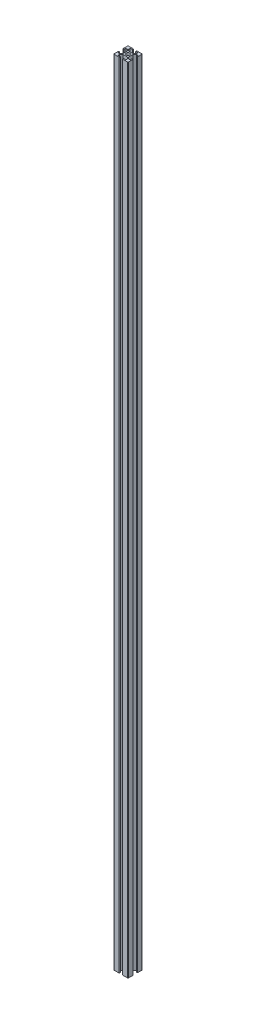
from build123d import *

# Parameters (mm, degrees)
SKETCH_11_R           = 2.5
F_20_X_20_X_2_1_DEPTH = 1108


with BuildPart() as part:
    # 草图11 → 铝型材 20 X 20 X 2(1) (new body)
    with BuildSketch(Plane.XZ.offset(-1108)):
        with BuildLine():
            Line((-10, 9), (-10, 3.25))
            Line((-10, 3.25), (-8.5, 3.25))
            Line((-8.5, 3.25), (-8.5, 5.5))
            Line((-8.5, 5.5), (-6.348528137, 5.5))
            Line((-6.348528137, 5.5), (-4, 3.151471863))
            Line((-4, 3.151471863), (-4, -3.151471863))
            Line((-4, -3.151471863), (-6.348528137, -5.5))
            Line((-6.348528137, -5.5), (-8.5, -5.5))
            Line((-8.5, -5.5), (-8.5, -3.25))
            Line((-8.5, -3.25), (-10, -3.25))
            Line((-10, -3.25), (-10, -9))
            ThreePointArc((-10, -9), (-9.707106781, -9.707106781), (-9, -10))
            Line((-9, -10), (-2.25, -10))
            Line((-2.25, -10), (-2.25, -8.5))
            Line((-2.25, -8.5), (-5.5, -8.5))
            Line((-5.5, -8.5), (-5.5, -6.348528137))
            Line((-5.5, -6.348528137), (-3.151471863, -4))
            Line((-3.151471863, -4), (3.151471863, -4))
            Line((3.151471863, -4), (5.5, -6.348528137))
            Line((5.5, -6.348528137), (5.5, -8.5))
            Line((5.5, -8.5), (2.25, -8.5))
            Line((2.25, -8.5), (2.25, -10))
            Line((2.25, -10), (9, -10))
            ThreePointArc((9, -10), (9.707106781, -9.707106781), (10, -9))
            Line((10, -9), (10, -3.25))
            Line((10, -3.25), (8.5, -3.25))
            Line((8.5, -3.25), (8.5, -5.5))
            Line((8.5, -5.5), (6.348528137, -5.5))
            Line((6.348528137, -5.5), (4, -3.151471863))
            Line((4, -3.151471863), (4, 3.151471863))
            Line((4, 3.151471863), (6.348528137, 5.5))
            Line((6.348528137, 5.5), (8.5, 5.5))
            Line((8.5, 5.5), (8.5, 3.25))
            Line((8.5, 3.25), (10, 3.25))
            Line((10, 3.25), (10, 9))
            ThreePointArc((10, 9), (9.707106781, 9.707106781), (9, 10))
            Line((9, 10), (2.25, 10))
            Line((2.25, 10), (2.25, 8.5))
            Line((2.25, 8.5), (5.5, 8.5))
            Line((5.5, 8.5), (5.5, 6.348528137))
            Line((5.5, 6.348528137), (3.151471863, 4))
            Line((3.151471863, 4), (-3.151471863, 4))
            Line((-3.151471863, 4), (-5.5, 6.348528137))
            Line((-5.5, 6.348528137), (-5.5, 8.5))
            Line((-5.5, 8.5), (-2.25, 8.5))
            Line((-2.25, 8.5), (-2.25, 10))
            Line((-2.25, 10), (-9, 10))
            ThreePointArc((-9, 10), (-9.707106781, 9.707106781), (-10, 9))
        make_face()
        Circle(SKETCH_11_R, mode=Mode.SUBTRACT)
    extrude(amount=F_20_X_20_X_2_1_DEPTH)


solid = part.part
